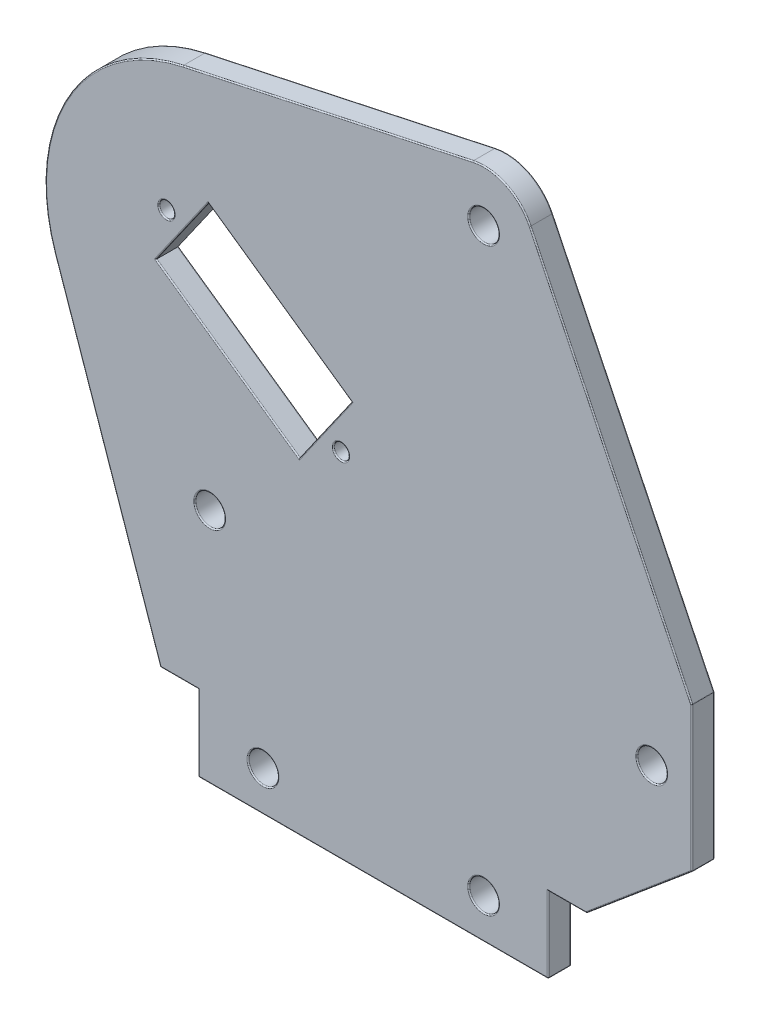
from build123d import *

# Parameters (mm, degrees)
SZKIC1_R                    = 1
DODANIE_WYCI_GNI_CIE1_DEPTH = 3
OTW_R_POD_RUB_M3_51_D       = 3.9
ZAOKR_GLENIE1_R             = 0.15


with BuildPart() as part:
    # Szkic1 → Dodanie-wyciągnięcie1 (new body)
    with BuildSketch(Plane.XY):
        with BuildLine():
            Line((28, 10), (41.85, 21.621529892))
            Line((41.85, 21.621529892), (41.85, 40.621529892))
            Line((41.85, 40.621529892), (20.610605748, 84.460506273))
            ThreePointArc((20.610605748, 84.460506273), (17.477220077, 87.602479874), (13.072325527, 88.138211024))
            Line((13.072325527, 88.138211024), (-25.029728066, 79.943634341))
            ThreePointArc((-25.029728066, 79.943634341), (-40.146654928, 68.813612437), (-41.843761624, 50.118193368))
            Line((-41.843761624, 50.118193368), (-28, 10))
            Line((-28, 10), (-23, 10))
            Line((-23, 10), (-23, 0))
            Line((-23, 0), (23, 0))
            Line((23, 0), (23, 10))
            Line((23, 10), (28, 10))
        make_face()
        with Locations((-27.182792376, 62.455399709)):
            Circle(SZKIC1_R, mode=Mode.SUBTRACT)
        with Locations((-4.246535136, 46.395259491)):
            Circle(SZKIC1_R, mode=Mode.SUBTRACT)
        Polygon((-21.693453648, 65.936370884), (-28.576370884, 56.106546352), (-9.735873865, 42.914288316), (-2.852956629, 52.744112848), align=None, mode=Mode.SUBTRACT)
    extrude(amount=DODANIE_WYCI_GNI_CIE1_DEPTH)

    # Otwór pod śrubę M3.51 (through all)
    with Locations(Plane.XY.offset(3)):
        with Locations((14.5, 81.5), (36.6, 31.121529892), (-21.5, 31.121529892), (14.5, 5.25), (-14.5, 5.25)):
            Hole(OTW_R_POD_RUB_M3_51_D / 2)

    # Zaokrąglenie1
    zaokr_glenie1_edges = [part.edges().sort_by_distance(p)[0] for p in [
        (41.85, 31.121529892, 3),
        (23, 5, 0),
        (0, 0, 0),
        (-23, 5, 0),
        (-25.5, 10, 0),
        (-34.921880812, 30.059096684, 0),
        (-40.146654928, 68.813612437, 0),
        (31.230302874, 62.541018083, 3),
        (-5.978701269, 84.040922682, 0),
        (17.477220077, 87.602479874, 0),
        (31.230302874, 62.541018083, 0),
        (41.85, 31.121529892, 0),
        (34.925, 15.810764946, 0),
        (25.5, 10, 0),
        (17.477220077, 87.602479874, 3),
        (-5.978701269, 84.040922682, 3),
        (23, 0, 1.5),
        (-23, 0, 1.5),
        (-28, 10, 1.5),
        (41.85, 40.621529892, 1.5),
        (41.85, 21.621529892, 1.5),
        (28, 10, 1.5),
        (-40.146654928, 68.813612437, 3),
        (-34.921880812, 30.059096684, 3),
        (-25.5, 10, 3),
        (-23, 5, 3),
        (-12.273205138, 59.340241866, 0),
        (-25.134912266, 61.021458618, 0),
        (-19.156122375, 49.510417334, 0),
        (-6.294415247, 47.829200582, 0),
        (0, 0, 3),
        (-12.273205138, 59.340241866, 3),
        (-25.134912266, 61.021458618, 3),
        (-19.156122375, 49.510417334, 3),
        (-6.294415247, 47.829200582, 3),
        (23, 5, 3),
        (25.5, 10, 3),
        (-28.182792376, 62.455399709, 0),
        (-28.182792376, 62.455399709, 3),
        (-5.246535136, 46.395259491, 0),
        (-5.246535136, 46.395259491, 3),
        (-12.55, 5.25, 3),
        (-12.55, 5.25, 0),
        (16.45, 5.25, 3),
        (16.45, 5.25, 0),
        (-19.55, 31.121529892, 3),
        (-19.55, 31.121529892, 0),
        (34.925, 15.810764946, 3),
        (38.55, 31.121529892, 3),
        (38.55, 31.121529892, 0),
        (16.45, 81.5, 3),
        (16.45, 81.5, 0),
    ]]
    fillet(zaokr_glenie1_edges, radius=ZAOKR_GLENIE1_R)


solid = part.part
